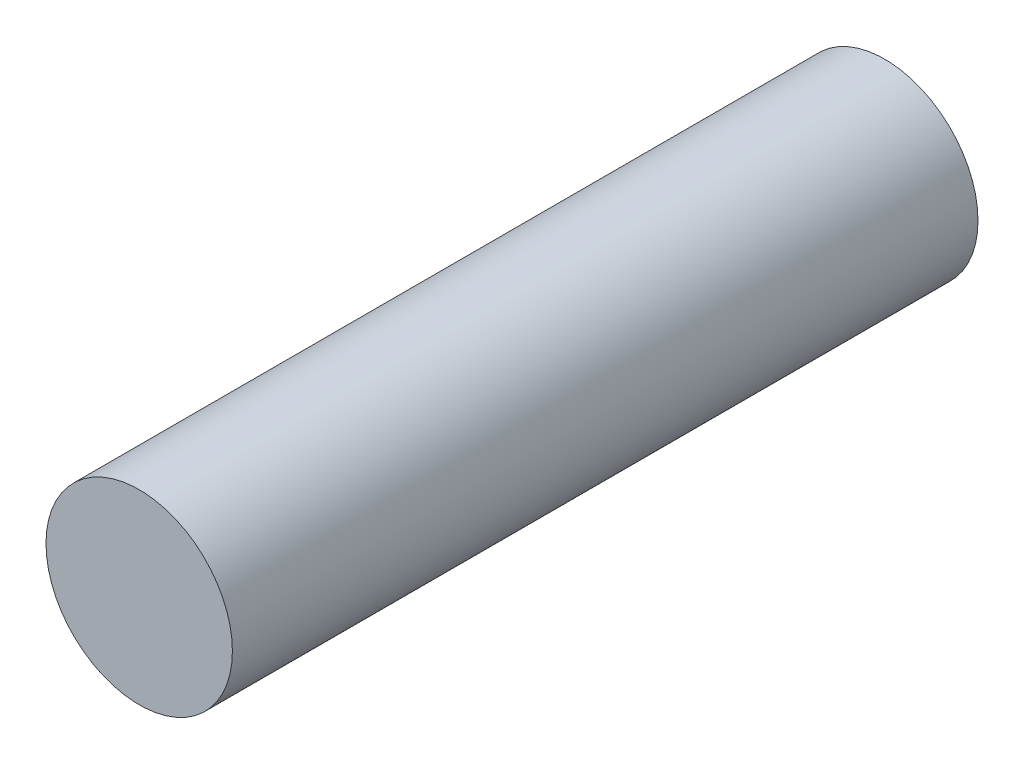
from build123d import *

# Parameters (mm, degrees)
ESQUISSE1_R        = 0.5
BOSS_EXTRU_1_DEPTH = 4


with BuildPart() as part:
    # Esquisse1 → Boss.-Extru.1 (new body)
    with BuildSketch(Plane.XY):
        Circle(ESQUISSE1_R)
    extrude(amount=BOSS_EXTRU_1_DEPTH)


solid = part.part
